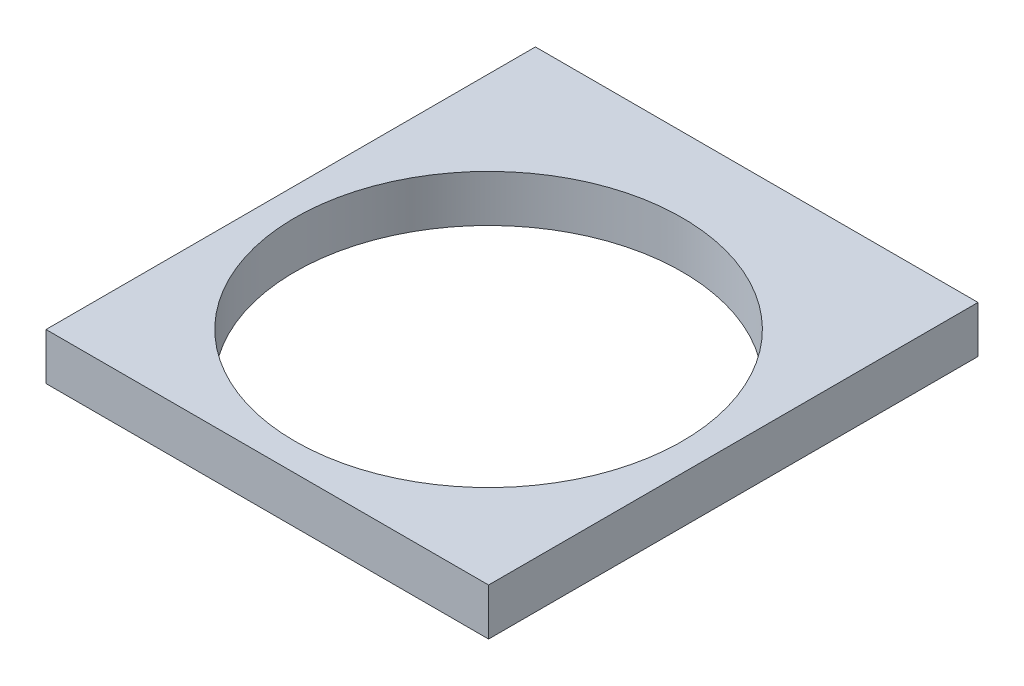
from build123d import *

# Parameters (mm, degrees)
SKETCH1_R           = 26.25
BOSS_EXTRUDE2_DEPTH = 6.35


with BuildPart() as part:
    # Sketch1 → Boss-Extrude2 (new body)
    with BuildSketch(Plane(origin=(0, 0, 0), x_dir=(1, 0, 0), z_dir=(0, 1, 0))):
        Polygon((-30, 30), (-30, 36.35), (30, 36.35), (30, 30), (30, -30), (-30, -30), align=None)
        Circle(SKETCH1_R, mode=Mode.SUBTRACT)
    extrude(amount=BOSS_EXTRUDE2_DEPTH)


solid = part.part
